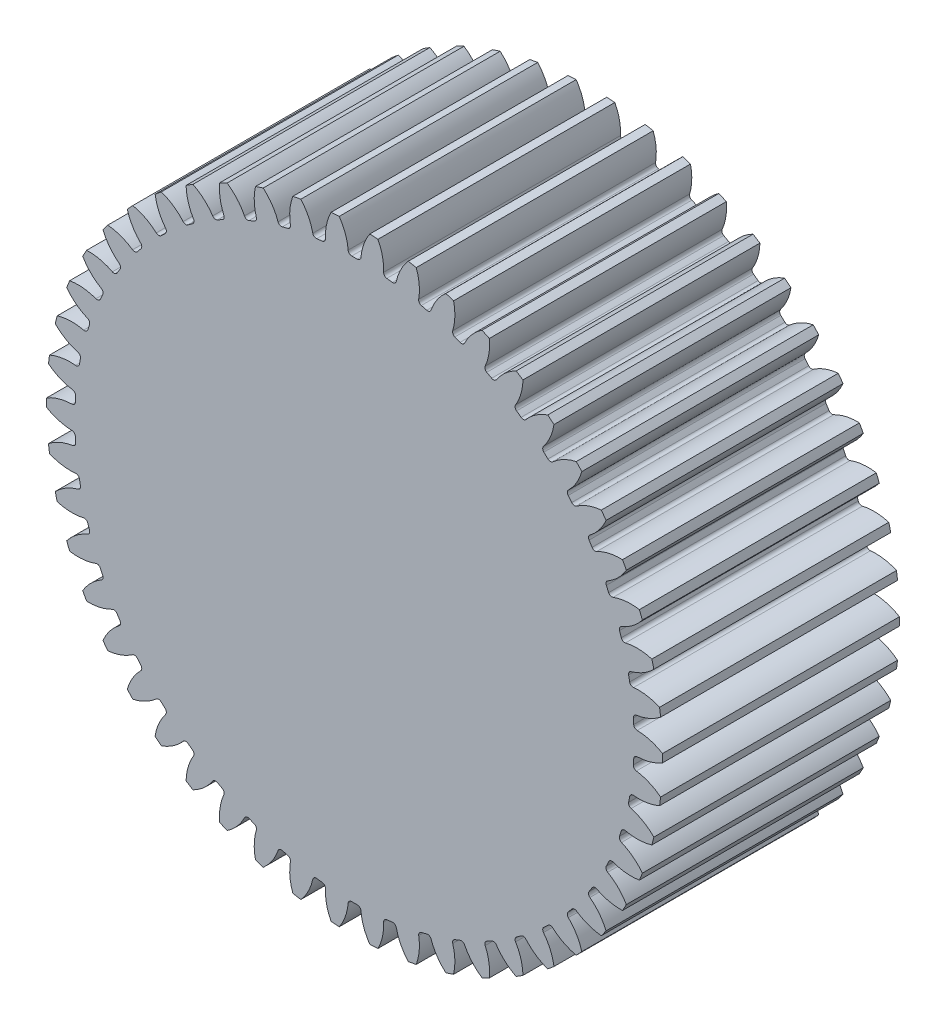
from build123d import *

# Parameters (mm, degrees)
CROQUIS1_R              = 26
SALIENTE_EXTRUIR1_DEPTH = 10
CORTAR_EXTRUIR1_DEPTH   = 11
REDONDEO1_R             = 0.3
MATRIZC1_COUNT          = 50
REDONDEO1_OF_MATRIZC1_R = 0.3


with BuildPart() as part:
    # Croquis1 → Saliente-Extruir1 (new body, symmetric)
    with BuildSketch(Plane.XY):
        Circle(CROQUIS1_R)
    extrude(amount=SALIENTE_EXTRUIR1_DEPTH, both=True)

    # Croquis2 → Cortar-Extruir1 (cut, symmetric)
    with BuildSketch(Plane.XY):
        with BuildLine():
            ThreePointArc((-0.523590474, 23.594191086), (-0.978233382, 25.437452419), (-2.173618599, 26.912364857))
            ThreePointArc((-2.173618599, 26.912364857), (0, 27), (2.173618599, 26.912364857))
            ThreePointArc((2.173618599, 26.912364857), (0.978233382, 25.437452419), (0.523590474, 23.594191086))
            ThreePointArc((0.523590474, 23.594191086), (0, 23.6), (-0.523590474, 23.594191086))
        make_face()
    cortar_extruir1 = extrude(amount=CORTAR_EXTRUIR1_DEPTH, both=True, mode=Mode.SUBTRACT)

    # Redondeo1
    redondeo1_edges = [part.edges().sort_by_distance(p)[0] for p in [
        (-0.523590474, 23.594191086, 0),
        (0.523590474, 23.594191086, 0),
    ]]
    fillet(redondeo1_edges, radius=REDONDEO1_R)

    # MatrizC1: Cortar-Extruir1 ×50 about axis
    matrizc1_axis = Axis((0, 0, 0), (0, 0, 1))
    for i in range(1, MATRIZC1_COUNT):
        add(cortar_extruir1.rotate(matrizc1_axis, i * 360 / MATRIZC1_COUNT), mode=Mode.SUBTRACT)

    # Redondeo1 of MatrizC1
    redondeo1_of_matrizc1_edges = [part.edges().sort_by_distance(p)[0] for p in [
        (-3.476598069, 23.342520555, 0),
        (-2.437674455, 23.47376713, 0),
        (-6.374777636, 22.722724531, 0),
        (-5.360495802, 22.983147843, 0),
        (-9.172423151, 21.744577566, 0),
        (-8.198778928, 22.130070585, 0),
        (-11.825414074, 20.423505624, 0),
        (-10.907762413, 20.927988894, 0),
        (-14.291911152, 18.780342798, 0),
        (-13.444723968, 19.395860316, 0),
        (-16.533016254, 16.841002747, 0),
        (-15.769654195, 17.557847435, 0),
        (-18.513385814, 14.636070023, 0),
        (-17.845887555, 15.442936811, 0),
        (-20.20178822, 12.200317731, 0),
        (-19.640680608, 13.084481849, 0),
        (-21.571596357, 9.57215914, 0),
        (-21.125728395, 10.519676791, 0),
        (-22.601207534, 6.793041882, 0),
        (-22.277610825, 7.788970147, 0),
        (-23.274384167, 3.906794295, 0),
        (-23.078162024, 4.93542679, 0),
        (-23.580509858, 0.958934228, 0),
        (-23.514756822, 2.004048804, 0),
        (-23.514756822, -2.004048804, 0),
        (-23.580509858, -0.958934228, 0),
        (-23.078162024, -4.93542679, 0),
        (-23.274384167, -3.906794295, 0),
        (-22.277610825, -7.788970147, 0),
        (-22.601207534, -6.793041882, 0),
        (-21.125728395, -10.519676791, 0),
        (-21.571596357, -9.57215914, 0),
        (-19.640680608, -13.084481849, 0),
        (-20.20178822, -12.200317731, 0),
        (-17.845887555, -15.442936811, 0),
        (-18.513385814, -14.636070023, 0),
        (-15.769654195, -17.557847435, 0),
        (-16.533016254, -16.841002747, 0),
        (-13.444723968, -19.395860316, 0),
        (-14.291911152, -18.780342798, 0),
        (-10.907762413, -20.927988894, 0),
        (-11.825414074, -20.423505624, 0),
        (-8.198778928, -22.130070585, 0),
        (-9.172423151, -21.744577566, 0),
        (-5.360495802, -22.983147843, 0),
        (-6.374777636, -22.722724531, 0),
        (-2.437674455, -23.47376713, 0),
        (-3.476598069, -23.342520555, 0),
        (0.523590474, -23.594191086, 0),
        (-0.523590474, -23.594191086, 0),
        (3.476598069, -23.342520555, 0),
        (2.437674455, -23.47376713, 0),
        (6.374777636, -22.722724531, 0),
        (5.360495802, -22.983147843, 0),
        (9.172423151, -21.744577566, 0),
        (8.198778928, -22.130070585, 0),
        (11.825414074, -20.423505624, 0),
        (10.907762413, -20.927988894, 0),
        (14.291911152, -18.780342798, 0),
        (13.444723968, -19.395860316, 0),
        (16.533016254, -16.841002747, 0),
        (15.769654195, -17.557847435, 0),
        (18.513385814, -14.636070023, 0),
        (17.845887555, -15.442936811, 0),
        (20.20178822, -12.200317731, 0),
        (19.640680608, -13.084481849, 0),
        (21.571596357, -9.57215914, 0),
        (21.125728395, -10.519676791, 0),
        (22.601207534, -6.793041882, 0),
        (22.277610825, -7.788970147, 0),
        (23.274384167, -3.906794295, 0),
        (23.078162024, -4.93542679, 0),
        (23.580509858, -0.958934228, 0),
        (23.514756822, -2.004048804, 0),
        (23.514756822, 2.004048804, 0),
        (23.580509858, 0.958934228, 0),
        (23.078162024, 4.93542679, 0),
        (23.274384167, 3.906794295, 0),
        (22.277610825, 7.788970147, 0),
        (22.601207534, 6.793041882, 0),
        (21.125728395, 10.519676791, 0),
        (21.571596357, 9.57215914, 0),
        (19.640680608, 13.084481849, 0),
        (20.20178822, 12.200317731, 0),
        (17.845887555, 15.442936811, 0),
        (18.513385814, 14.636070023, 0),
        (15.769654195, 17.557847435, 0),
        (16.533016254, 16.841002747, 0),
        (13.444723968, 19.395860316, 0),
        (14.291911152, 18.780342798, 0),
        (10.907762413, 20.927988894, 0),
        (11.825414074, 20.423505624, 0),
        (8.198778928, 22.130070585, 0),
        (9.172423151, 21.744577566, 0),
        (5.360495802, 22.983147843, 0),
        (6.374777636, 22.722724531, 0),
        (2.437674455, 23.47376713, 0),
        (3.476598069, 23.342520555, 0),
    ]]
    fillet(redondeo1_of_matrizc1_edges, radius=REDONDEO1_OF_MATRIZC1_R)


solid = part.part
